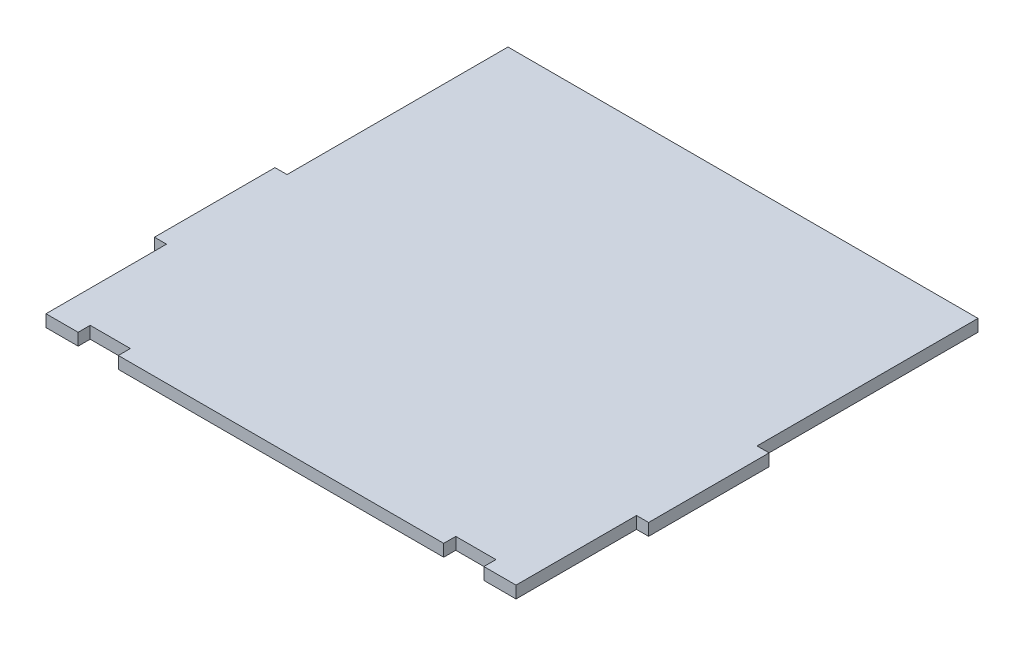
from build123d import *

# Parameters (mm, degrees)
BOSS_EXTRUDE1_DEPTH = 3


with BuildPart() as part:
    # Sketch1 → Boss-Extrude1 (new body)
    with BuildSketch(Plane(origin=(0, 0, 0), x_dir=(1, 0, 0), z_dir=(0, 1, 0))):
        Polygon((-50.598751805, -26.831932773), (-50.598751805, 3.168067227), (-53.598751805, 3.168067227), (-53.598751805, 33.168067227), (-50.598751805, 33.168067227), (-50.598751805, 88.168067227), (66.401248195, 88.168067227), (66.401248195, 33.168067227), (69.401248195, 33.168067227), (69.401248195, 3.168067227), (66.401248195, 3.168067227), (66.401248195, -26.831932773), (58.401248195, -26.831932773), (58.401248195, -23.831932773), (48.401248195, -23.831932773), (48.401248195, -26.831932773), (-32.598751805, -26.831932773), (-32.598751805, -23.831932773), (-42.598751805, -23.831932773), (-42.598751805, -26.831932773), align=None)
    extrude(amount=BOSS_EXTRUDE1_DEPTH)


solid = part.part
